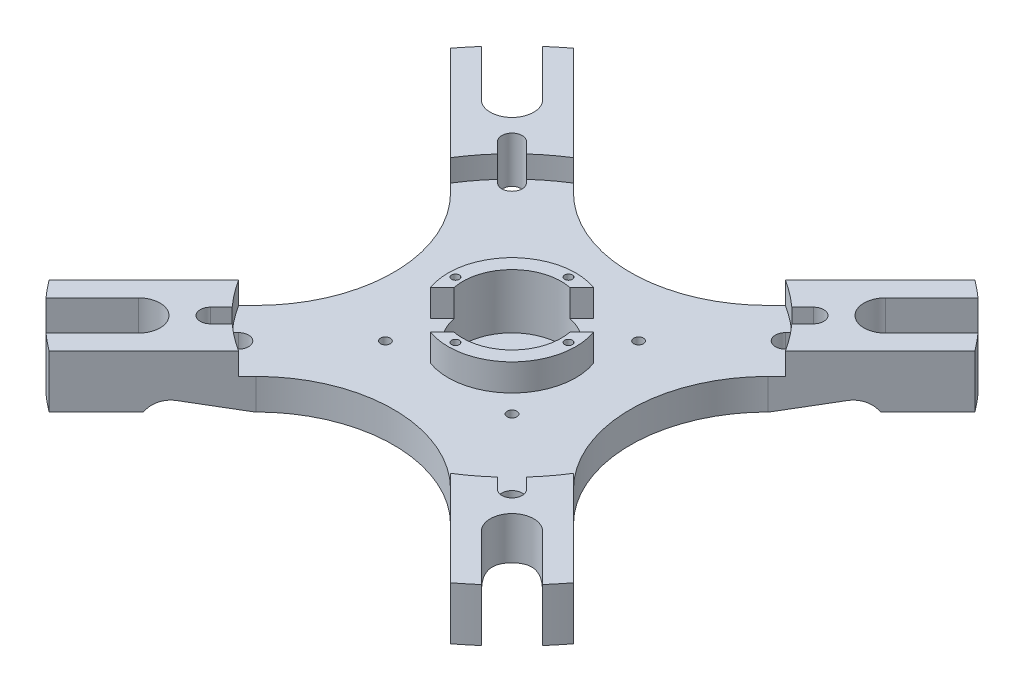
from build123d import *

# Parameters (mm, degrees)
SKETCH1_W                 = 403.225
SKETCH1_H                 = 403.225
BOSS_EXTRUDE1_DEPTH       = 12.192
FILLET1_R                 = 38.1
CUT_EXTRUDE1_DEPTH        = 12.192
SKETCH3_R                 = 45.72
CUT_EXTRUDE2_DEPTH        = 5.08
SKETCH5_R                 = 11.3665
CUT_EXTRUDE4_DEPTH        = 6.4262
SKETCH6_R                 = 4.7117
CUT_EXTRUDE5_DEPTH        = 1.6858
BOSS_EXTRUDE2_DEPTH       = 6.223
F_2_56_TAPPED_HOLE1_D     = 1.778
F_2_56_TAPPED_HOLE1_DEPTH = 5.588
F_2_56_TAPPED_HOLE1_TIP   = 0.53416509
F_4_40_TAPPED_HOLE1_D     = 2.2606
CUT_EXTRUDE6_DEPTH        = 2.143
CUT_EXTRUDE6_DEPTH_BACK   = 13.192
CUT_EXTRUDE10_DEPTH       = 14.335
SKETCH15_R                = 269.341595118
SKETCH15_R_2              = 76.2
CUT_EXTRUDE11_DEPTH       = 14.335


with BuildPart() as part:
    # Sketch1 → Boss-Extrude1 (new body)
    with BuildSketch(Plane(origin=(0, 0, 0), x_dir=(1, 0, 0), z_dir=(0, 1, 0))):
        Rectangle(SKETCH1_W, SKETCH1_H)
    extrude(amount=BOSS_EXTRUDE1_DEPTH)

    # Fillet1
    fillet1_edges = [part.edges().sort_by_distance(p)[0] for p in [
        (-201.6125, 6.096, -201.6125),
        (201.6125, 6.096, -201.6125),
        (201.6125, 6.096, 201.6125),
        (-201.6125, 6.096, 201.6125),
    ]]
    fillet(fillet1_edges, radius=FILLET1_R)

    # Sketch2 → Cut-Extrude1 (cut)
    with BuildSketch(Plane(origin=(0, 12.192, 0), x_dir=(1, 0, 0), z_dir=(0, 1, 0))):
        with BuildLine():
            Line((-191.9605, 113.38461962), (-191.9605, -113.38461962))
            ThreePointArc((-191.9605, -113.38461962), (-175.496667141, -138.024486752), (-146.431962146, -132.243157474))
            Line((-146.431962146, -132.243157474), (-36.639444974, -22.450640303))
            ThreePointArc((-36.639444974, -22.450640303), (-27.340085277, 0), (-36.639444974, 22.450640303))
            Line((-36.639444974, 22.450640303), (-146.431962146, 132.243157474))
            ThreePointArc((-146.431962146, 132.243157474), (-175.496667141, 138.024486752), (-191.9605, 113.38461962))
        make_face()
        with BuildLine():
            Line((-113.38461962, -191.9605), (113.38461962, -191.9605))
            ThreePointArc((113.38461962, -191.9605), (138.024486752, -175.496667141), (132.243157474, -146.431962146))
            Line((132.243157474, -146.431962146), (22.450640303, -36.639444974))
            ThreePointArc((22.450640303, -36.639444974), (0, -27.340085277), (-22.450640303, -36.639444974))
            Line((-22.450640303, -36.639444974), (-132.243157474, -146.431962146))
            ThreePointArc((-132.243157474, -146.431962146), (-138.024486752, -175.496667141), (-113.38461962, -191.9605))
        make_face()
        with BuildLine():
            ThreePointArc((146.431962146, 132.243157474), (175.496667141, 138.024486752), (191.9605, 113.38461962))
            Line((191.9605, 113.38461962), (191.9605, -113.38461962))
            ThreePointArc((191.9605, -113.38461962), (175.496667141, -138.024486752), (146.431962146, -132.243157474))
            Line((146.431962146, -132.243157474), (36.639444974, -22.450640303))
            ThreePointArc((36.639444974, -22.450640303), (27.340085277, 0), (36.639444974, 22.450640303))
            Line((36.639444974, 22.450640303), (146.431962146, 132.243157474))
        make_face()
        with BuildLine():
            Line((113.38461962, 191.9605), (-113.38461962, 191.9605))
            ThreePointArc((-113.38461962, 191.9605), (-138.024486752, 175.496667141), (-132.243157474, 146.431962146))
            Line((-132.243157474, 146.431962146), (-22.450640303, 36.639444974))
            ThreePointArc((-22.450640303, 36.639444974), (0, 27.340085277), (22.450640303, 36.639444974))
            Line((22.450640303, 36.639444974), (132.243157474, 146.431962146))
            ThreePointArc((132.243157474, 146.431962146), (138.024486752, 175.496667141), (113.38461962, 191.9605))
        make_face()
    extrude(amount=-CUT_EXTRUDE1_DEPTH, mode=Mode.SUBTRACT)

    # Sketch3 → Cut-Extrude2 (cut)
    with BuildSketch(Plane(origin=(0, 12.192, 0), x_dir=(1, 0, 0), z_dir=(0, 1, 0))):
        Circle(SKETCH3_R)
    extrude(amount=-CUT_EXTRUDE2_DEPTH, mode=Mode.SUBTRACT)

    # Sketch5 → Cut-Extrude4 (cut)
    with BuildSketch(Plane(origin=(0, 7.112, 0), x_dir=(1, 0, 0), z_dir=(0, 1, 0))):
        Circle(SKETCH5_R)
    extrude(amount=-CUT_EXTRUDE4_DEPTH, mode=Mode.SUBTRACT)

    # Sketch6 → Cut-Extrude5 (cut, through all)
    with BuildSketch(Plane(origin=(0, 0.6858, 0), x_dir=(1, 0, 0), z_dir=(0, 1, 0))):
        Circle(SKETCH6_R)
    extrude(amount=-CUT_EXTRUDE5_DEPTH, mode=Mode.SUBTRACT)

    # Sketch7 → Boss-Extrude2 (add)
    with BuildSketch(Plane(origin=(0, 7.112, 0), x_dir=(1, 0, 0), z_dir=(0, 1, 0))):
        with BuildLine():
            Line((2.176011086, 11.156267207), (4.909587999, 13.88984412))
            ThreePointArc((4.909587999, 13.88984412), (-10.4170971, 10.4170971), (-13.88984412, -4.909587999))
            Line((-13.88984412, -4.909587999), (-11.156267207, -2.176011086))
            ThreePointArc((-11.156267207, -2.176011086), (-8.037329228, 8.037329228), (2.176011086, 11.156267207))
        make_face()
        with BuildLine():
            Line((11.156267207, 2.176011086), (13.88984412, 4.909587999))
            ThreePointArc((13.88984412, 4.909587999), (10.4170971, -10.4170971), (-4.909587999, -13.88984412))
            Line((-4.909587999, -13.88984412), (-2.176011086, -11.156267207))
            ThreePointArc((-2.176011086, -11.156267207), (8.037329228, -8.037329228), (11.156267207, 2.176011086))
        make_face()
    extrude(amount=BOSS_EXTRUDE2_DEPTH)

    # #2-56 Tapped Hole1
    with Locations(Plane(origin=(0, 13.335, 0), x_dir=(1, 0, 0), z_dir=(0, 1, 0))):
        with Locations((0, 13.04925), (-13.04925, 0), (0, -13.04925), (13.04925, 0)):
            Hole(F_2_56_TAPPED_HOLE1_D / 2, depth=F_2_56_TAPPED_HOLE1_DEPTH)
            with Locations((0, 0, -(F_2_56_TAPPED_HOLE1_DEPTH + F_2_56_TAPPED_HOLE1_TIP / 2))):  # 118° drill point
                Cone(0, F_2_56_TAPPED_HOLE1_D / 2, F_2_56_TAPPED_HOLE1_TIP, mode=Mode.SUBTRACT)

    # #4-40 Tapped Hole1 (through all)
    with Locations(Plane(origin=(0, 7.112, 0), x_dir=(1, 0, 0), z_dir=(0, 1, 0))):
        with Locations((-14.605, 14.605), (14.605, 14.605), (-14.605, -14.605), (14.605, -14.605)):
            Hole(F_4_40_TAPPED_HOLE1_D / 2)

    # Sketch12 → Cut-Extrude6 (cut, two sides)
    with BuildSketch(Plane(origin=(0, 12.192, 0), x_dir=(1, 0, 0), z_dir=(0, 1, 0))) as cut_extrude6_sk:
        with BuildLine():
            Line((36.459839852, 33.137145087), (33.226947648, 29.904252883))
            ThreePointArc((33.226947648, 29.904252883), (29.904252883, 29.904252883), (29.904252883, 33.226947648))
            Line((29.904252883, 33.226947648), (33.137145087, 36.459839852))
            ThreePointArc((33.137145087, 36.459839852), (36.459839852, 36.459839852), (36.459839852, 33.137145087))
        make_face()
        with BuildLine():
            Line((33.137145087, -36.459839852), (29.904252883, -33.226947648))
            ThreePointArc((29.904252883, -33.226947648), (29.904252883, -29.904252883), (33.226947648, -29.904252883))
            Line((33.226947648, -29.904252883), (36.459839852, -33.137145087))
            ThreePointArc((36.459839852, -33.137145087), (36.459839852, -36.459839852), (33.137145087, -36.459839852))
        make_face()
        with BuildLine():
            Line((-36.459839852, -33.137145087), (-33.226947648, -29.904252883))
            ThreePointArc((-33.226947648, -29.904252883), (-29.904252883, -29.904252883), (-29.904252883, -33.226947648))
            Line((-29.904252883, -33.226947648), (-33.137145087, -36.459839852))
            ThreePointArc((-33.137145087, -36.459839852), (-36.459839852, -36.459839852), (-36.459839852, -33.137145087))
        make_face()
        with BuildLine():
            Line((-33.137145087, 36.459839852), (-29.904252883, 33.226947648))
            ThreePointArc((-29.904252883, 33.226947648), (-29.904252883, 29.904252883), (-33.226947648, 29.904252883))
            Line((-33.226947648, 29.904252883), (-36.459839852, 33.137145087))
            ThreePointArc((-36.459839852, 33.137145087), (-36.459839852, 36.459839852), (-33.137145087, 36.459839852))
        make_face()
    extrude(amount=CUT_EXTRUDE6_DEPTH, mode=Mode.SUBTRACT)
    extrude(cut_extrude6_sk.sketch, amount=-CUT_EXTRUDE6_DEPTH_BACK, mode=Mode.SUBTRACT)

    # Sketch13 → Cut-Revolve1 (revolve, cut)
    with BuildSketch(Plane.XY):
        with BuildLine():
            Line((43.18, 0), (55.626, 2.286))
            ThreePointArc((55.626, 2.286), (58.638160635, 1.948374814), (60.96, 0))
            Line((60.96, 0), (43.18, 0))
        make_face()
    revolve(axis=Axis((0, 0, 0), (0, 1, 0)), mode=Mode.SUBTRACT)

    # Sketch14 → Cut-Extrude10 (cut, through all)
    with BuildSketch(Plane.XZ):
        with BuildLine():
            Line((-39.575988726, 46.634470037), (-141.052882894, 148.111364205))
            ThreePointArc((-141.052882894, 148.111364205), (-148.111364205, 148.111364205), (-148.111364205, 141.052882894))
            Line((-148.111364205, 141.052882894), (-46.634470037, 39.575988726))
            ThreePointArc((-46.634470037, 39.575988726), (-46.561476038, 39.504474147), (-46.487033217, 39.434468966))
            ThreePointArc((-46.487033217, 39.434468966), (-43.105229381, 43.105229381), (-39.434468966, 46.487033217))
            ThreePointArc((-39.434468966, 46.487033217), (-39.504474147, 46.561476038), (-39.575988726, 46.634470037))
        make_face()
        with BuildLine():
            Line((46.634470037, 39.575988726), (148.111364205, 141.052882894))
            ThreePointArc((148.111364205, 141.052882894), (148.111364205, 148.111364205), (141.052882894, 148.111364205))
            Line((141.052882894, 148.111364205), (39.575988726, 46.634470037))
            ThreePointArc((39.575988726, 46.634470037), (39.504474147, 46.561476038), (39.434468966, 46.487033217))
            ThreePointArc((39.434468966, 46.487033217), (43.105229381, 43.105229381), (46.487033217, 39.434468966))
            ThreePointArc((46.487033217, 39.434468966), (46.561476038, 39.504474147), (46.634470037, 39.575988726))
        make_face()
        with BuildLine():
            ThreePointArc((39.434468966, 46.487033217), (39.575988726, 39.575988726), (46.487033217, 39.434468966))
            ThreePointArc((46.487033217, 39.434468966), (43.105229381, 43.105229381), (39.434468966, 46.487033217))
        make_face()
        with BuildLine():
            ThreePointArc((-46.487033217, 39.434468966), (-39.575988726, 39.575988726), (-39.434468966, 46.487033217))
            ThreePointArc((-39.434468966, 46.487033217), (-43.105229381, 43.105229381), (-46.487033217, 39.434468966))
        make_face()
        with BuildLine():
            Line((39.575988726, -46.634470037), (141.052882894, -148.111364205))
            ThreePointArc((141.052882894, -148.111364205), (148.111364205, -148.111364205), (148.111364205, -141.052882894))
            Line((148.111364205, -141.052882894), (46.634470037, -39.575988726))
            ThreePointArc((46.634470037, -39.575988726), (46.561476038, -39.504474147), (46.487033217, -39.434468966))
            ThreePointArc((46.487033217, -39.434468966), (43.105229381, -43.105229381), (39.434468966, -46.487033217))
            ThreePointArc((39.434468966, -46.487033217), (39.504474147, -46.561476038), (39.575988726, -46.634470037))
        make_face()
        with BuildLine():
            ThreePointArc((46.487033217, -39.434468966), (39.575988726, -39.575988726), (39.434468966, -46.487033217))
            ThreePointArc((39.434468966, -46.487033217), (43.105229381, -43.105229381), (46.487033217, -39.434468966))
        make_face()
        with BuildLine():
            ThreePointArc((-39.434468966, -46.487033217), (-39.575988726, -39.575988726), (-46.487033217, -39.434468966))
            ThreePointArc((-46.487033217, -39.434468966), (-43.105229381, -43.105229381), (-39.434468966, -46.487033217))
        make_face()
        with BuildLine():
            Line((-46.634470037, -39.575988726), (-148.111364205, -141.052882894))
            ThreePointArc((-148.111364205, -141.052882894), (-148.111364205, -148.111364205), (-141.052882894, -148.111364205))
            Line((-141.052882894, -148.111364205), (-39.575988726, -46.634470037))
            ThreePointArc((-39.575988726, -46.634470037), (-39.504474147, -46.561476038), (-39.434468966, -46.487033217))
            ThreePointArc((-39.434468966, -46.487033217), (-43.105229381, -43.105229381), (-46.487033217, -39.434468966))
            ThreePointArc((-46.487033217, -39.434468966), (-46.561476038, -39.504474147), (-46.634470037, -39.575988726))
        make_face()
    extrude(amount=-CUT_EXTRUDE10_DEPTH, mode=Mode.SUBTRACT)

    # Sketch15 → Cut-Extrude11 (cut, through all)
    with BuildSketch(Plane.XZ):
        Circle(SKETCH15_R)
        Circle(SKETCH15_R_2, mode=Mode.SUBTRACT)
    extrude(amount=-CUT_EXTRUDE11_DEPTH, mode=Mode.SUBTRACT)


solid = part.part
